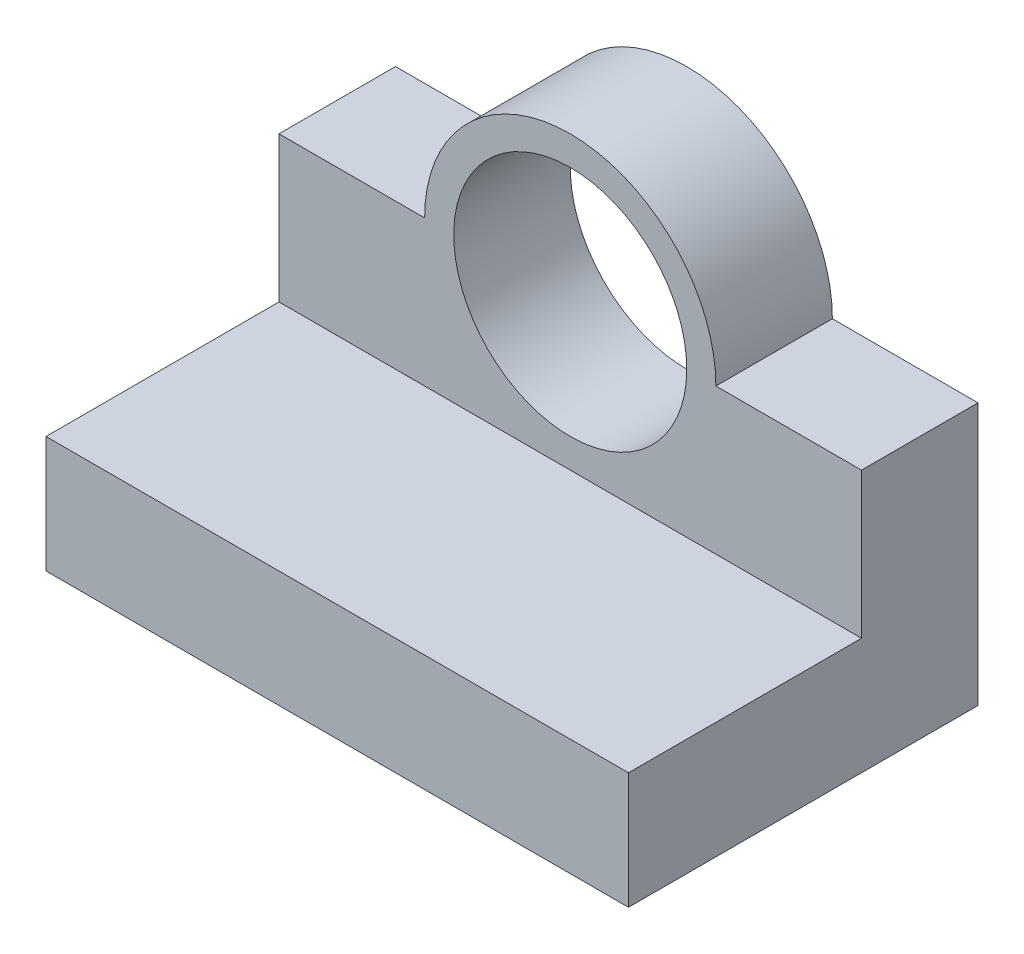
from build123d import *

# Parameters (mm, degrees)
BOSS_EXTRUDE1_DEPTH     = 100
CUT_EXTRUDE1_DEPTH      = 21
SKETCH3_R               = 20
CUT_EXTRUDE3_DEPTH      = 41
CUT_EXTRUDE3_DEPTH_BACK = 21


with BuildPart() as part:
    # Sketch1 → Boss-Extrude1 (new body)
    with BuildSketch(Plane(origin=(0, 0, 0), x_dir=(0, 0, -1), z_dir=(1, 0, 0))):
        Polygon((10, 35), (10, -15), (-30, -15), (-30, -35), (30, -35), (30, 35), align=None)
    extrude(amount=BOSS_EXTRUDE1_DEPTH)

    # Sketch2 → Cut-Extrude1 (cut, through all)
    with BuildSketch(Plane.XY.offset(-10)):
        with BuildLine():
            Line((0, 35), (0, 10))
            Line((0, 10), (25, 10))
            ThreePointArc((25, 10), (32.32233047, 27.67766953), (50, 35))
            Line((50, 35), (0, 35))
        make_face()
        with BuildLine():
            Line((100, 35), (50, 35))
            ThreePointArc((50, 35), (67.67766953, 27.67766953), (75, 10))
            Line((75, 10), (100, 10))
            Line((100, 10), (100, 35))
        make_face()
    extrude(amount=-CUT_EXTRUDE1_DEPTH, mode=Mode.SUBTRACT)

    # Sketch3 → Cut-Extrude3 (cut, two sides)
    with BuildSketch(Plane.XY.offset(-10)) as cut_extrude3_sk:
        with Locations((50, 10)):
            Circle(SKETCH3_R)
    extrude(amount=CUT_EXTRUDE3_DEPTH, mode=Mode.SUBTRACT)
    extrude(cut_extrude3_sk.sketch, amount=-CUT_EXTRUDE3_DEPTH_BACK, mode=Mode.SUBTRACT)


solid = part.part
